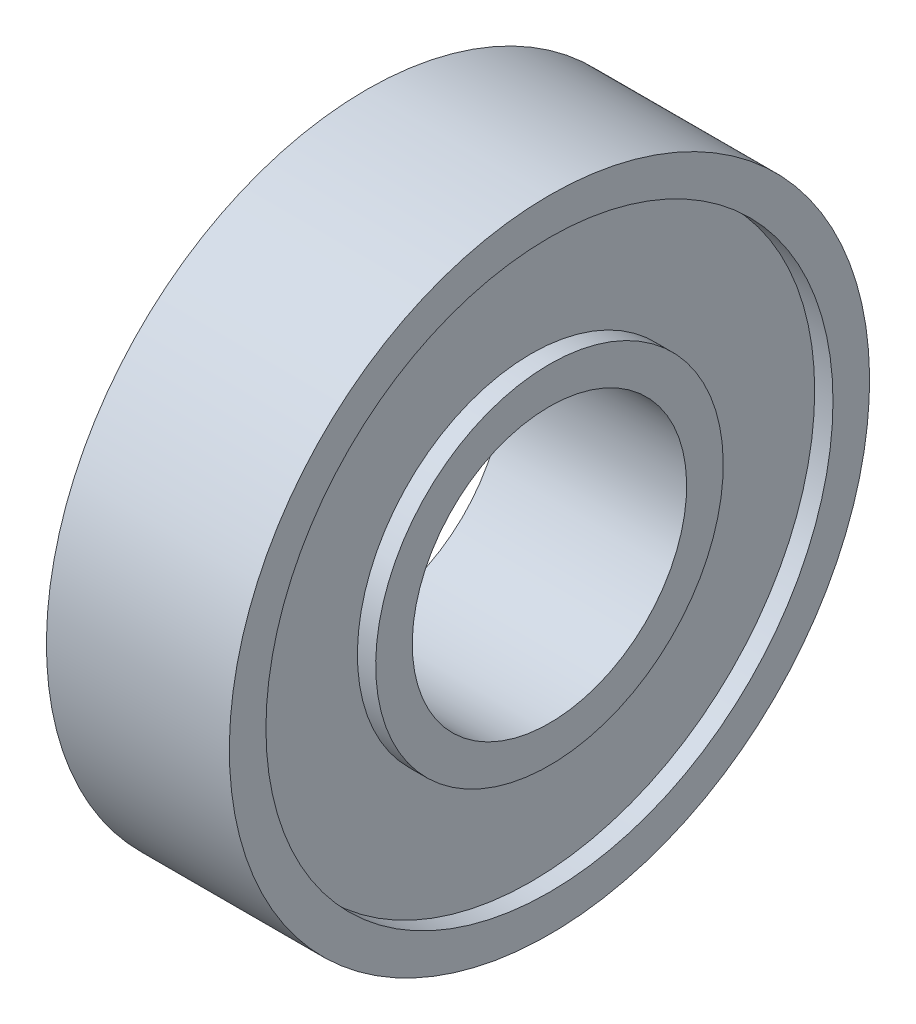
from build123d import *


with BuildPart() as part:
    # Sketch1 → Revolve1 (revolve)
    with BuildSketch(Plane.XY):
        Polygon((-4, 6), (4, 6), (4, 7.6), (3.2, 7.6), (3.2, 12.4), (4, 12.4), (4, 14), (-4, 14), (-4, 12.4), (-3.2, 12.4), (-3.2, 7.6), (-4, 7.6), align=None)
    revolve(axis=Axis((6.481208189, 0, 0), (-1, 0, 0)))


solid = part.part
